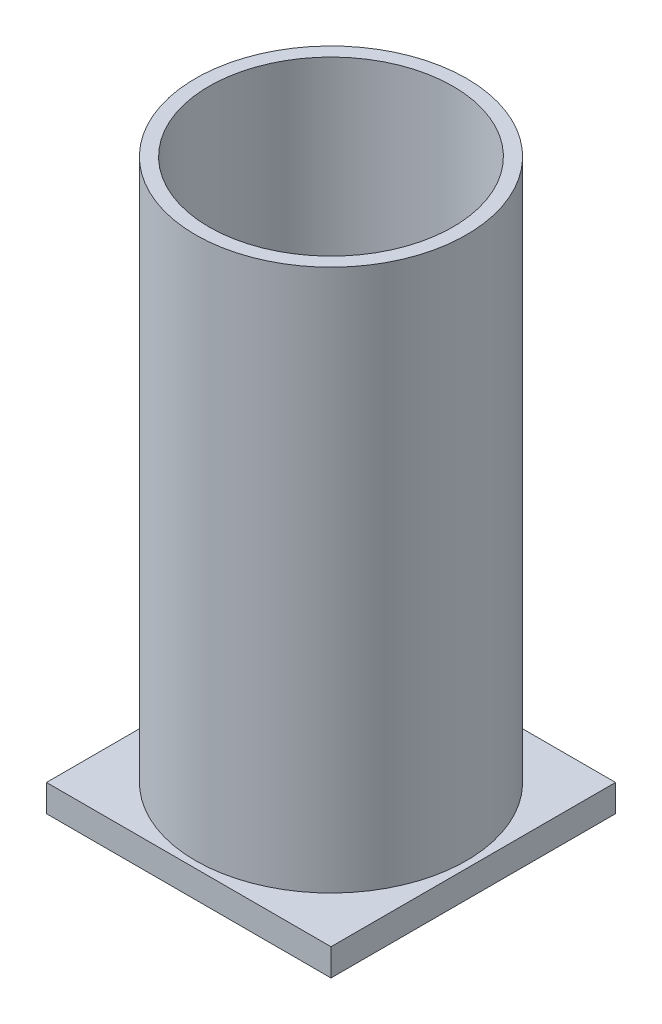
from build123d import *

# Parameters (mm, degrees)
SKETCH2_R           = 50
SKETCH2_R_2         = 45
BOSS_EXTRUDE3_DEPTH = 200
SKETCH4_W           = 105
SKETCH4_H           = 105
BOSS_EXTRUDE5_DEPTH = 10


with BuildPart() as part:
    # Sketch2 → Boss-Extrude3 (new body)
    with BuildSketch(Plane(origin=(0, 0, 0), x_dir=(1, 0, 0), z_dir=(0, 1, 0))):
        Circle(SKETCH2_R)
        Circle(SKETCH2_R_2, mode=Mode.SUBTRACT)
    extrude(amount=BOSS_EXTRUDE3_DEPTH)

    # Sketch4 → Boss-Extrude5 (add)
    with BuildSketch(Plane(origin=(0, 0, 0), x_dir=(1, 0, 0), z_dir=(0, 1, 0))):
        Rectangle(SKETCH4_W, SKETCH4_H)
    extrude(amount=-BOSS_EXTRUDE5_DEPTH)


solid = part.part
